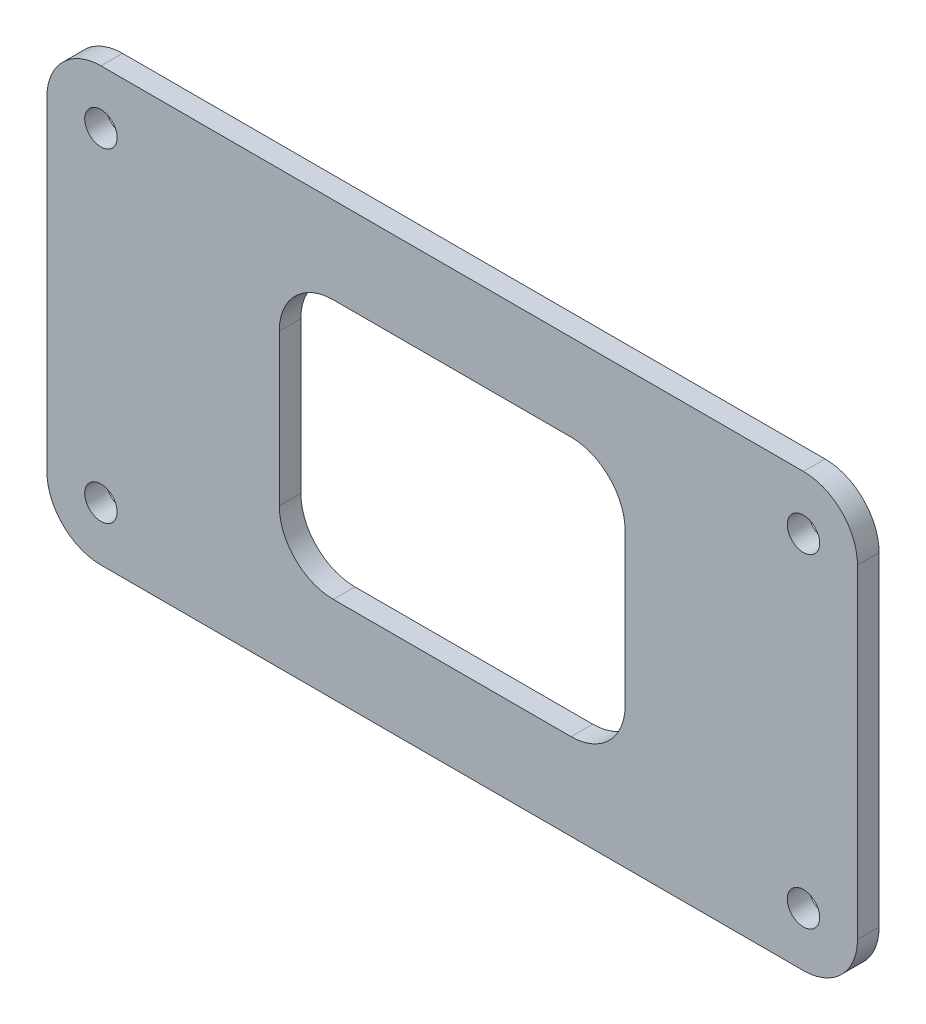
from build123d import *

# Parameters (mm, degrees)
SKETCH1_R           = 1.5
BOSS_EXTRUDE1_DEPTH = 2


with BuildPart() as part:
    # Sketch1 → Boss-Extrude1 (new body)
    with BuildSketch(Plane.XY):
        with BuildLine():
            Line((32.5, 20), (-32.5, 20))
            ThreePointArc((-32.5, 20), (-36.035533906, 18.535533906), (-37.5, 15))
            Line((-37.5, 15), (-37.5, -15))
            ThreePointArc((-37.5, -15), (-36.035533906, -18.535533906), (-32.5, -20))
            Line((-32.5, -20), (32.5, -20))
            ThreePointArc((32.5, -20), (36.035533906, -18.535533906), (37.5, -15))
            Line((37.5, -15), (37.5, 15))
            ThreePointArc((37.5, 15), (36.035533906, 18.535533906), (32.5, 20))
        make_face()
        with Locations((-32.5, -15)):
            Circle(SKETCH1_R, mode=Mode.SUBTRACT)
        with Locations((-32.5, 15)):
            Circle(SKETCH1_R, mode=Mode.SUBTRACT)
        with Locations((32.5, 15)):
            Circle(SKETCH1_R, mode=Mode.SUBTRACT)
        with Locations((32.5, -15)):
            Circle(SKETCH1_R, mode=Mode.SUBTRACT)
        with BuildLine():
            Line((-11, 12), (11, 12))
            ThreePointArc((11, 12), (14.535533906, 10.535533906), (16, 7))
            Line((16, 7), (16, -7))
            ThreePointArc((16, -7), (14.535533906, -10.535533906), (11, -12))
            Line((11, -12), (-11, -12))
            ThreePointArc((-11, -12), (-14.535533906, -10.535533906), (-16, -7))
            Line((-16, -7), (-16, 7))
            ThreePointArc((-16, 7), (-14.535533906, 10.535533906), (-11, 12))
        make_face(mode=Mode.SUBTRACT)
    extrude(amount=BOSS_EXTRUDE1_DEPTH)


solid = part.part
